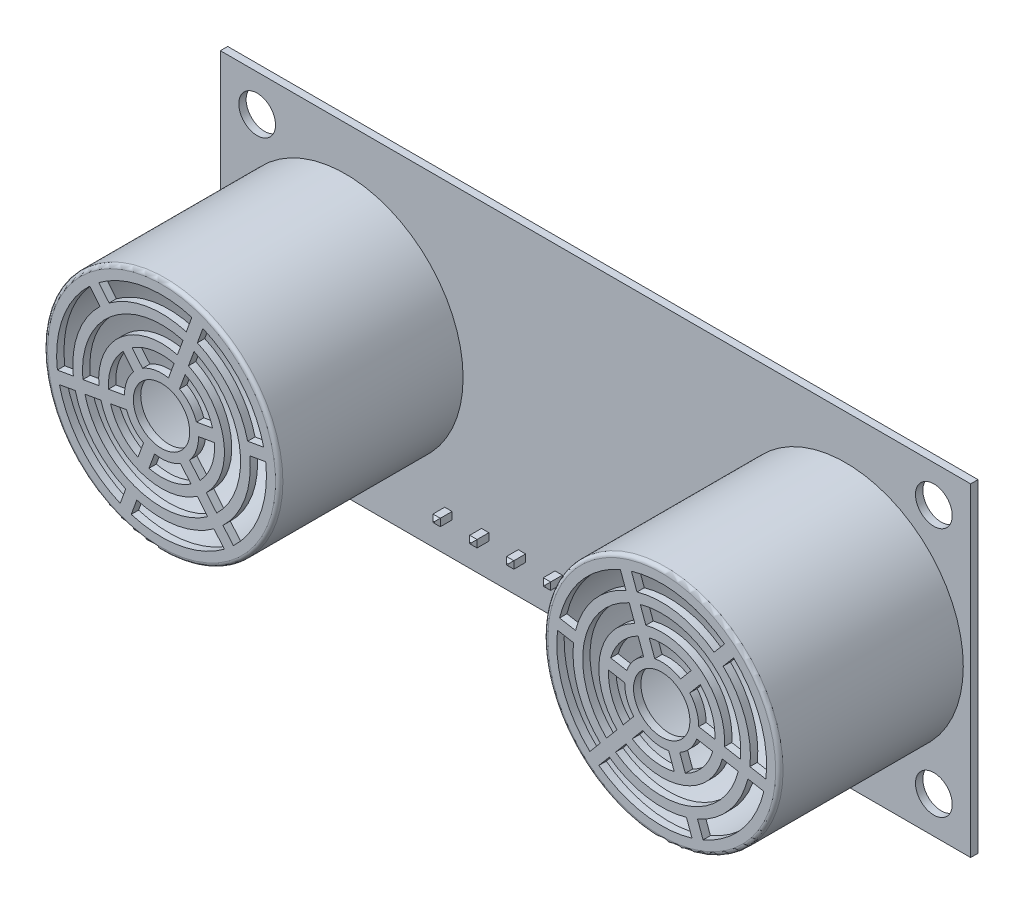
from build123d import *

# Parameters (mm, degrees)
SKETCH_1_W               = 51
SKETCH_1_H               = 22
SKETCH_1_R               = 1.25
EXTRUDE_1_DEPTH          = 0.5
SKETCH_2_R               = 8
EXTRUDE_2_DEPTH          = 12.5
SHELL_1_T                = -0.5
SKETCH_3_R               = 7.131472647
SKETCH_3_R_2             = 6.031472647
SKETCH_3_R_3             = 5.374142557
SKETCH_3_R_4             = 4.274142557
SKETCH_3_R_5             = 3.614937472
SKETCH_3_R_6             = 2.514937472
CUT_EXTRUDE_1_DEPTH      = 0.5
EXTRUDE_3_DEPTH          = 0.5
PATTERN_CIRCULAR_2_COUNT = 3
FILLET_1_R               = 0.25
SKETCH_5_R               = 1.914937472
CUT_EXTRUDE_1_2_DEPTH    = 0.5
EXTRUDE_START            = -0.5
SKETCH_6_W               = 2.5
SKETCH_6_H               = 2.5
SKETCH_6_W_2             = 0.5
SKETCH_6_H_2             = 0.5
EXTRUDE_3_2_DEPTH        = 2
SKETCH_6_2_W             = 0.5
SKETCH_6_2_H             = 0.5
EXTRUDE_5_DEPTH          = 1
EXTRUDE_5_DEPTH_BACK     = 10
CHAMFER_1_SIZE           = 0.2
PATTERN_LINEAR_1_COUNT   = 5
PATTERN_LINEAR_1_PITCH   = 2.5
PATTERN_LINEAR_1_2_COUNT = 5
PATTERN_LINEAR_1_2_PITCH = 2.5


with BuildPart() as part:
    # Эскиз1 → Бобышка-Вытянуть1 (new body)
    with BuildSketch(Plane.XY):
        Rectangle(SKETCH_1_W, SKETCH_1_H)
        with Locations((-23, 8.5)):
            Circle(SKETCH_1_R, mode=Mode.SUBTRACT)
        with Locations(Location((-23, -8.5, 0), (0, 0, 180))):
            Circle(SKETCH_1_R, mode=Mode.SUBTRACT)
        with Locations(Location((23, 8.5, 0), (0, 0, 180))):
            Circle(SKETCH_1_R, mode=Mode.SUBTRACT)
        with Locations((23, -8.5)):
            Circle(SKETCH_1_R, mode=Mode.SUBTRACT)
    extrude(amount=-EXTRUDE_1_DEPTH)


with BuildPart() as body_2:
    # Эскиз2 → Бобышка-Вытянуть2 (new body)
    with BuildSketch(Plane.XY):
        with Locations(Location((-17, 0, 0), (0, 0, 180))):
            Circle(SKETCH_2_R)
    extrude(amount=EXTRUDE_2_DEPTH)

    # Оболочка1
    shell_1_openings = [body_2.faces().sort_by_distance(p)[0] for p in [
        (-17, 0, 0),
    ]]
    offset(amount=SHELL_1_T, openings=shell_1_openings, kind=Kind.INTERSECTION)

    # Эскиз3 → Cut-Extrude 1 (cut)
    with BuildSketch(Plane.XY.offset(12.5)):
        with Locations((-17, 0)):
            Circle(SKETCH_3_R)
        with Locations((-17, 0)):
            Circle(SKETCH_3_R_2, mode=Mode.SUBTRACT)
        with Locations((-17, 0)):
            Circle(SKETCH_3_R_3)
        with Locations((-17, 0)):
            Circle(SKETCH_3_R_4, mode=Mode.SUBTRACT)
        with Locations((-17, 0)):
            Circle(SKETCH_3_R_5)
        with Locations((-17, 0)):
            Circle(SKETCH_3_R_6, mode=Mode.SUBTRACT)
    extrude(amount=-CUT_EXTRUDE_1_DEPTH, mode=Mode.SUBTRACT)


with BuildPart() as cut_extrude_1_piece_1:
    # of the separate pieces the step leaves, piece 1, a body of its own (cut_extrude_1_pieces)
    add(body_2.part.solids().sort_by_distance((-25, 0, 0))[0])



with BuildPart() as cut_extrude_1_piece_2:
    # of the separate pieces the step leaves, piece 2, a body of its own (cut_extrude_1_pieces)
    add(body_2.part.solids().sort_by_distance((-10.968527353, 0, 12.5))[0])


with BuildPart() as cut_extrude_1_piece_3:
    # of the separate pieces the step leaves, piece 3, a body of its own (cut_extrude_1_pieces)
    add(body_2.part.solids().sort_by_distance((-14.485062528, 0, 12.5))[0])


with BuildPart() as cut_extrude_1_piece_4:
    # of the separate pieces the step leaves, piece 4, a body of its own (cut_extrude_1_pieces)
    add(body_2.part.solids().sort_by_distance((-12.725857443, 0, 12.5))[0])


with BuildPart() as cut_extrude_1_piece_1_1:
    add(cut_extrude_1_piece_1.part)

    add(cut_extrude_1_piece_2.part)  # Extrude 3 merges Cut-Extrude 1 piece 2

    add(cut_extrude_1_piece_3.part)  # Extrude 3 merges Cut-Extrude 1 piece 3

    add(cut_extrude_1_piece_4.part)  # Extrude 3 merges Cut-Extrude 1 piece 4
    # Эскиз4 → Extrude 3 (add)
    with BuildSketch(Plane.XY.offset(12.5)):
        Polygon((-13.509440822, 1.021650406), (-17.751754097, 0.273616115), (-12.722395521, -5.720140036), (-12.109559966, -5.205909949), (-16.248245903, -0.273616115), (-13.37052228, 0.233804203), align=None)
        Polygon((-11.638043473, 0.53928696), (-9.907411176, 0.844444128), (-10.046329718, 1.63229033), (-11.776962015, 1.327133163), align=None)
    extrude_3 = extrude(amount=-EXTRUDE_3_DEPTH)

    # Круговой массив2: Extrude 3 ×3 about axis
    pattern_circular_2_axis = Axis((-17, 0, 0), (0, 0, 1))
    for i in range(1, PATTERN_CIRCULAR_2_COUNT):
        add(extrude_3.rotate(pattern_circular_2_axis, i * 360 / PATTERN_CIRCULAR_2_COUNT))

    # Скругление1
    fillet_1_edges = [cut_extrude_1_piece_1_1.edges().sort_by_distance(p)[0] for p in [
        (-9, 0, 12.5),
    ]]
    fillet(fillet_1_edges, radius=FILLET_1_R)

    # Эскиз5 → Cut-Extrude 1 2 (cut)
    with BuildSketch(Plane.XY.offset(12.5)):
        with Locations((-17, 0)):
            Circle(SKETCH_5_R)
    extrude(amount=-CUT_EXTRUDE_1_2_DEPTH, mode=Mode.SUBTRACT)


with BuildPart() as body_3:
    # Зеркальное отражение1: mirrored copy
    add(cut_extrude_1_piece_1_1.part.mirror(Plane(origin=(0, 0, 0), x_dir=(0, 0, 1), z_dir=(1, 0, 0))))


with BuildPart() as body_4:
    # Эскиз6 → Extrude 3 2 (new body)
    with BuildSketch(Plane.XY.offset(EXTRUDE_START)):
        with Locations((0, -8.5)):
            Rectangle(SKETCH_6_W, SKETCH_6_H)
        with Locations((0, -8.5)):
            Rectangle(SKETCH_6_W_2, SKETCH_6_H_2, mode=Mode.SUBTRACT)
    extrude(amount=-EXTRUDE_3_2_DEPTH)


with BuildPart() as body_5:
    # Эскиз6<2> → Бобышка-Вытянуть5 (new, two sides)
    with BuildSketch(Plane.XY) as extrude_5_sk:
        with Locations((0, -8.5)):
            Rectangle(SKETCH_6_2_W, SKETCH_6_2_H)
    extrude(amount=EXTRUDE_5_DEPTH)
    extrude(extrude_5_sk.sketch, amount=-EXTRUDE_5_DEPTH_BACK)

    # Фаска1
    chamfer_1_edges = [body_5.edges().sort_by_distance(p)[0] for p in [
        (0, -8.25, 1),
        (0, -8.25, -10),
        (-0.25, -8.5, 1),
        (0, -8.75, 1),
        (0.25, -8.5, 1),
        (-0.25, -8.5, -10),
        (0, -8.75, -10),
        (0.25, -8.5, -10),
    ]]
    chamfer(chamfer_1_edges, length=CHAMFER_1_SIZE)


with BuildPart() as pattern_linear_1_1:
    # Линейный массив1: pattern copy
    add(body_5.part.moved(Location(Vector(1, 0, 0) * (1 * PATTERN_LINEAR_1_PITCH))))


with BuildPart() as pattern_linear_1_2:
    # Линейный массив1: pattern copy
    add(body_5.part.moved(Location(Vector(1, 0, 0) * (2 * PATTERN_LINEAR_1_PITCH))))


with BuildPart() as pattern_linear_1_3:
    # Линейный массив1: pattern copy
    add(body_5.part.moved(Location(Vector(1, 0, 0) * (3 * PATTERN_LINEAR_1_PITCH))))


with BuildPart() as pattern_linear_1_4:
    # Линейный массив1: pattern copy
    add(body_5.part.moved(Location(Vector(1, 0, 0) * (4 * PATTERN_LINEAR_1_PITCH))))


with BuildPart() as pattern_linear_1_5:
    # Линейный массив1: pattern copy
    add(body_4.part.moved(Location(Vector(1, 0, 0) * (1 * PATTERN_LINEAR_1_PITCH))))


with BuildPart() as pattern_linear_1_6:
    # Линейный массив1: pattern copy
    add(body_4.part.moved(Location(Vector(1, 0, 0) * (2 * PATTERN_LINEAR_1_PITCH))))


with BuildPart() as pattern_linear_1_7:
    # Линейный массив1: pattern copy
    add(body_4.part.moved(Location(Vector(1, 0, 0) * (3 * PATTERN_LINEAR_1_PITCH))))


with BuildPart() as pattern_linear_1_8:
    # Линейный массив1: pattern copy
    add(body_4.part.moved(Location(Vector(1, 0, 0) * (4 * PATTERN_LINEAR_1_PITCH))))


with BuildPart() as pattern_linear_1_2_1:
    # Pattern Linear 1 2: pattern copy
    add(body_5.part.moved(Location(Vector(-1, 0, 0) * (1 * PATTERN_LINEAR_1_2_PITCH))))


with BuildPart() as pattern_linear_1_2_2:
    # Pattern Linear 1 2: pattern copy
    add(body_5.part.moved(Location(Vector(-1, 0, 0) * (2 * PATTERN_LINEAR_1_2_PITCH))))


with BuildPart() as pattern_linear_1_2_3:
    # Pattern Linear 1 2: pattern copy
    add(body_5.part.moved(Location(Vector(-1, 0, 0) * (3 * PATTERN_LINEAR_1_2_PITCH))))


with BuildPart() as pattern_linear_1_2_4:
    # Pattern Linear 1 2: pattern copy
    add(body_5.part.moved(Location(Vector(-1, 0, 0) * (4 * PATTERN_LINEAR_1_2_PITCH))))


with BuildPart() as pattern_linear_1_2_5:
    # Pattern Linear 1 2: pattern copy
    add(body_4.part.moved(Location(Vector(-1, 0, 0) * (1 * PATTERN_LINEAR_1_2_PITCH))))


with BuildPart() as pattern_linear_1_2_6:
    # Pattern Linear 1 2: pattern copy
    add(body_4.part.moved(Location(Vector(-1, 0, 0) * (2 * PATTERN_LINEAR_1_2_PITCH))))


with BuildPart() as pattern_linear_1_2_7:
    # Pattern Linear 1 2: pattern copy
    add(body_4.part.moved(Location(Vector(-1, 0, 0) * (3 * PATTERN_LINEAR_1_2_PITCH))))


with BuildPart() as pattern_linear_1_2_8:
    # Pattern Linear 1 2: pattern copy
    add(body_4.part.moved(Location(Vector(-1, 0, 0) * (4 * PATTERN_LINEAR_1_2_PITCH))))


solid = Compound([part.part, cut_extrude_1_piece_1_1.part, body_3.part, body_4.part, body_5.part, pattern_linear_1_1.part, pattern_linear_1_2.part, pattern_linear_1_3.part, pattern_linear_1_4.part, pattern_linear_1_5.part, pattern_linear_1_6.part, pattern_linear_1_7.part, pattern_linear_1_8.part, pattern_linear_1_2_1.part, pattern_linear_1_2_2.part, pattern_linear_1_2_3.part, pattern_linear_1_2_4.part, pattern_linear_1_2_5.part, pattern_linear_1_2_6.part, pattern_linear_1_2_7.part, pattern_linear_1_2_8.part])
